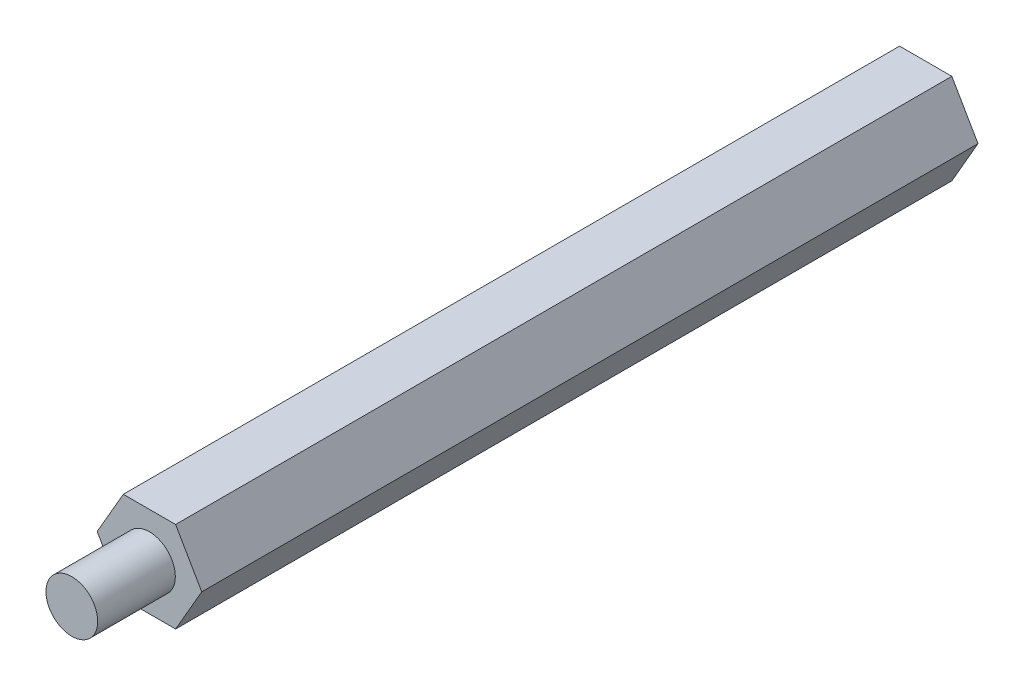
from build123d import *

# Parameters (mm, degrees)
EXTRUDE_1_DEPTH = 60
SKETCH_2_R      = 2
EXTRUDE_2_DEPTH = 6
M4X0_7_1_D      = 3.3
M4X0_7_1_DEPTH  = 10.5
M4X0_7_1_TIP    = 0.991420021


with BuildPart() as part:
    # 草圖1 → 填料-伸長1 (new body)
    with BuildSketch(Plane.XY):
        Polygon((4.041451884, 0), (2.020725942, 3.5), (-2.020725942, 3.5), (-4.041451884, 0), (-2.020725942, -3.5), (2.020725942, -3.5), align=None)
    extrude(amount=EXTRUDE_1_DEPTH)

    # 草圖2 → 填料-伸長2 (add)
    with BuildSketch(Plane.XY.offset(60)):
        Circle(SKETCH_2_R)
    extrude(amount=EXTRUDE_2_DEPTH)

    # M4x0.7 螺紋孔1
    with Locations(Plane(origin=(0, 0, 0), x_dir=(-1, 0, 0), z_dir=(0, 0, -1))):
        with Locations((0, 0)):
            Hole(M4X0_7_1_D / 2, depth=M4X0_7_1_DEPTH)
            with Locations((0, 0, -(M4X0_7_1_DEPTH + M4X0_7_1_TIP / 2))):  # 118° drill point
                Cone(0, M4X0_7_1_D / 2, M4X0_7_1_TIP, mode=Mode.SUBTRACT)


solid = part.part
